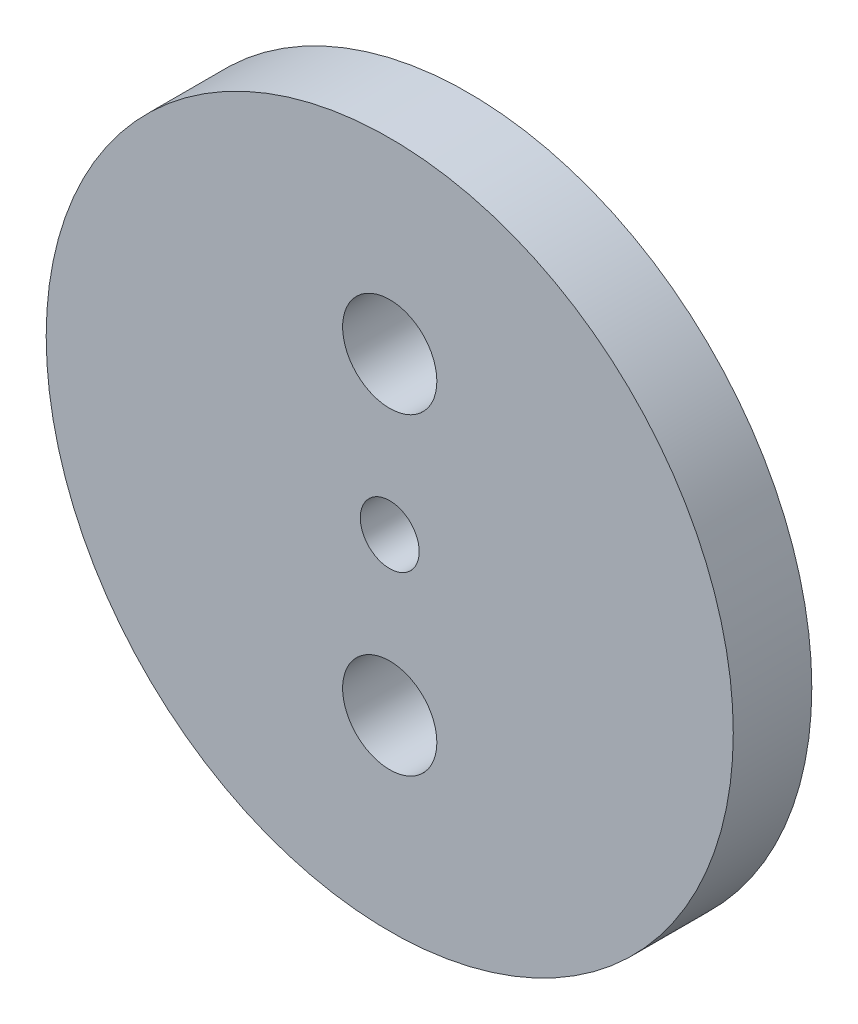
from build123d import *

# Parameters (mm, degrees)
SKETCH1_R           = 17.5
SKETCH1_R_2         = 2.4
SKETCH1_R_3         = 1.5
BOSS_EXTRUDE1_DEPTH = 4


with BuildPart() as part:
    # Sketch1 → Boss-Extrude1 (new body)
    with BuildSketch(Plane.XY):
        Circle(SKETCH1_R)
        with Locations((0, 7.97)):
            Circle(SKETCH1_R_2, mode=Mode.SUBTRACT)
        with Locations((0, -7.97)):
            Circle(SKETCH1_R_2, mode=Mode.SUBTRACT)
        Circle(SKETCH1_R_3, mode=Mode.SUBTRACT)
    extrude(amount=BOSS_EXTRUDE1_DEPTH)


solid = part.part
